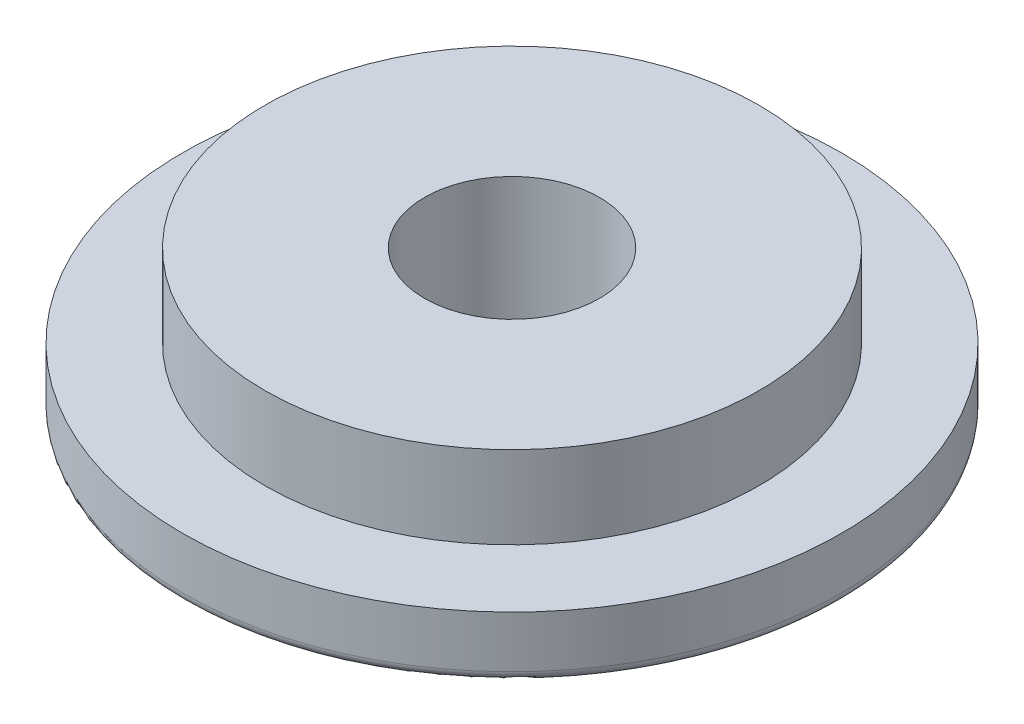
from build123d import *

# Parameters (mm, degrees)
SKETCH2_R          = 6.746875
CUT_EXTRUDE1_DEPTH = 12.1252


with BuildPart() as part:
    # Sketch1 → Revolve1 (revolve)
    with BuildSketch(Plane.XY):
        with BuildLine():
            Line((0, 0), (0, 11.1252))
            Line((0, 11.1252), (19.05, 11.1252))
            Line((19.05, 11.1252), (19.05, 4.7752))
            Line((19.05, 4.7752), (25.4, 4.7752))
            Line((25.4, 4.7752), (25.4, 0.79375))
            ThreePointArc((25.4, 0.79375), (25.167516008, 0.232483992), (24.60625, 0))
            Line((24.60625, 0), (0, 0))
        make_face()
    revolve(axis=Axis((0, 140.214345547, 0), (0, -1, 0)))

    # Sketch2 → Cut-Extrude1 (cut, through all)
    with BuildSketch(Plane(origin=(0, 11.1252, 0), x_dir=(1, 0, 0), z_dir=(0, 1, 0))):
        Circle(SKETCH2_R)
    extrude(amount=-CUT_EXTRUDE1_DEPTH, mode=Mode.SUBTRACT)


solid = part.part
